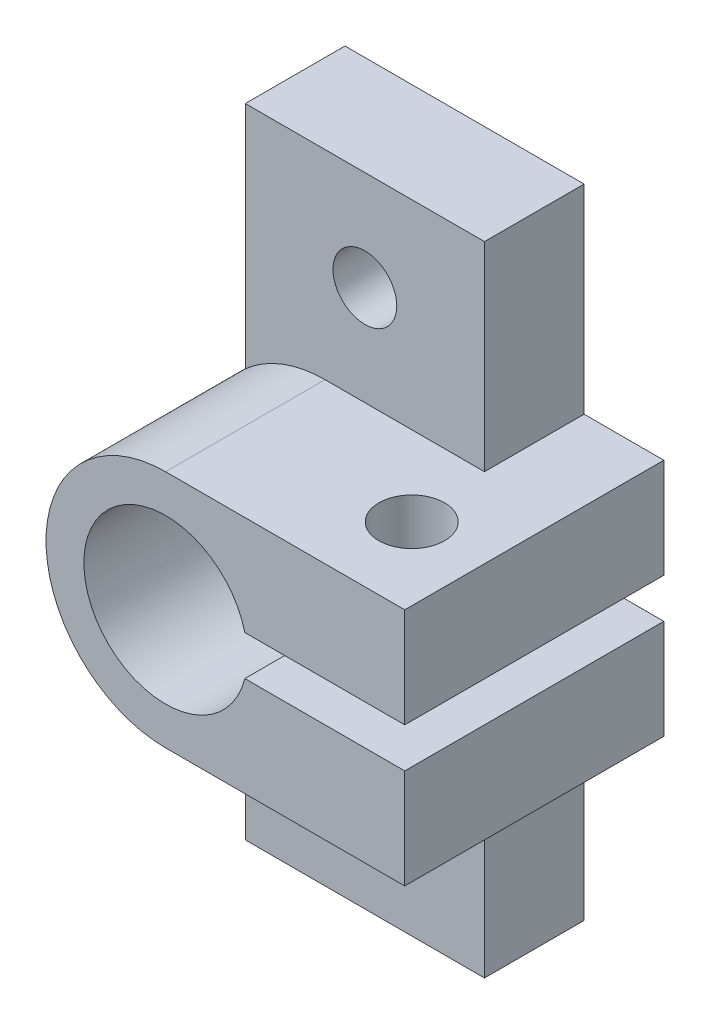
from build123d import *

# Parameters (mm, degrees)
ESBO_O1_R                     = 1.6
RESSALTO_EXTRUS_O1_DEPTH      = 5
RESSALTO_EXTRUS_O1_2_DEPTH    = 5
RESSALTO_EXTRUS_O2_DEPTH      = 8
RESSALTO_EXTRUS_O2_DEPTH_BACK = 5
ESBO_O3_R                     = 1.65
CORTE_EXTRUS_O1_DEPTH         = 23
CORTE_EXTRUS_O1_DEPTH_BACK    = 11


with BuildPart() as part:
    # Esboço1 → Ressalto-extrusão1 (new body)
    with BuildSketch(Plane.XY):
        with BuildLine():
            ThreePointArc((-4, -0.9), (-0.051399019, -4.099677809), (3.97617907, -1))
            Line((3.97617907, -1), (8, -1))
            Line((8, -1), (8, -16))
            Line((8, -16), (-4, -16))
            Line((-4, -16), (-4, -0.9))
        make_face()
        with Locations((2, -11)):
            Circle(ESBO_O1_R, mode=Mode.SUBTRACT)
    extrude(amount=RESSALTO_EXTRUS_O1_DEPTH)



with BuildPart() as body_2:
    # Esboço1 → Ressalto-extrus_o1 2 (new body)
    with BuildSketch(Plane.XY):
        with BuildLine():
            ThreePointArc((3.97617907, 1), (-0.051399019, 4.099677809), (-4, 0.9))
            Line((-4, 0.9), (-4, 16))
            Line((-4, 16), (8, 16))
            Line((8, 16), (8, 1))
            Line((8, 1), (3.97617907, 1))
        make_face()
        with Locations((2, 11)):
            Circle(ESBO_O1_R, mode=Mode.SUBTRACT)
    extrude(amount=RESSALTO_EXTRUS_O1_2_DEPTH)


with BuildPart() as part_1:
    add(part.part)

    add(body_2.part)  # Ressalto-extrusão2 merges body 2
    # Esboço2 → Ressalto-extrusão2 (add, two sides)
    with BuildSketch(Plane.XY.offset(5)) as ressalto_extrus_o2_sk:
        with BuildLine():
            Line((12, 6), (12, 1))
            Line((12, 1), (3.97617907, 1))
            ThreePointArc((3.97617907, 1), (-4.1, 0), (3.97617907, -1))
            Line((3.97617907, -1), (12, -1))
            Line((12, -1), (12, -6))
            Line((12, -6), (0, -6))
            ThreePointArc((0, -6), (-6, 0), (0, 6))
            Line((0, 6), (12, 6))
        make_face()
    extrude(amount=RESSALTO_EXTRUS_O2_DEPTH)
    extrude(ressalto_extrus_o2_sk.sketch, amount=-RESSALTO_EXTRUS_O2_DEPTH_BACK)

    # Esboço3 → Corte-extrusão1 (cut, two sides)
    with BuildSketch(Plane.XZ.offset(-6)) as corte_extrus_o1_sk:
        with Locations((8.35, 9)):
            Circle(ESBO_O3_R)
    extrude(amount=CORTE_EXTRUS_O1_DEPTH, mode=Mode.SUBTRACT)
    extrude(corte_extrus_o1_sk.sketch, amount=-CORTE_EXTRUS_O1_DEPTH_BACK, mode=Mode.SUBTRACT)


solid = part_1.part
